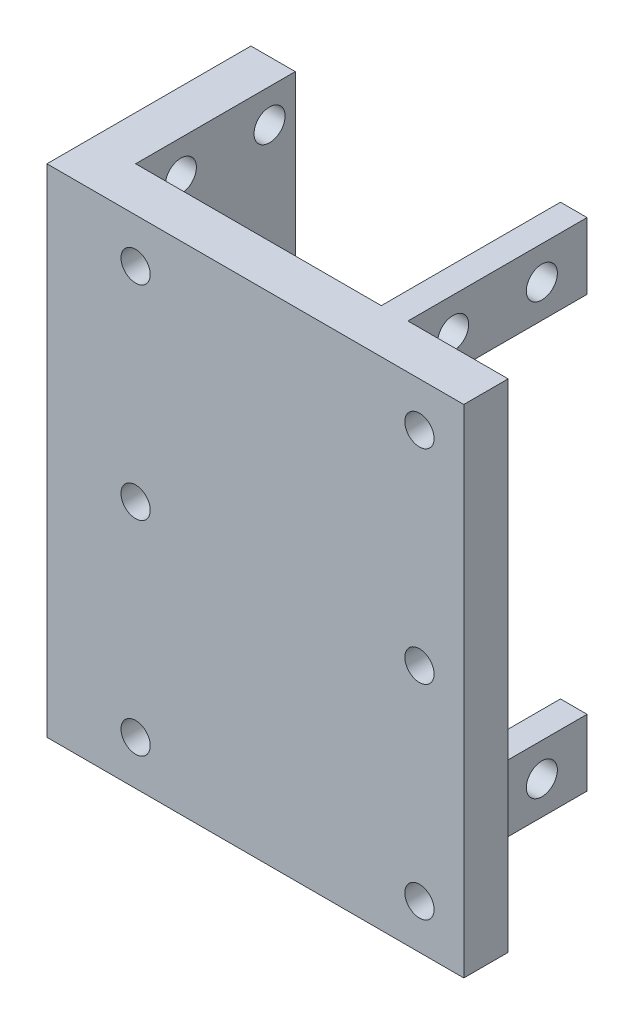
from build123d import *

# Parameters (mm, degrees)
SKETCH_1_W          = 42
SKETCH_1_H          = 56
EXTRUDE_1_DEPTH     = 5
SKETCH_2_W          = 5
SKETCH_2_H          = 56
EXTRUDE_2_DEPTH     = 23
SKETCH_3_W          = 3
SKETCH_3_H          = 7.5
EXTRUDE_3_DEPTH     = 20.2
SKETCH_4_R          = 1.75
CUT_EXTRUDE_1_DEPTH = 36.7
SKETCH_5_R          = 1.65
CUT_EXTRUDE_2_DEPTH = 10


with BuildPart() as part:
    # 草图1 → 凸台-拉伸1 (new body)
    with BuildSketch(Plane.XY):
        Rectangle(SKETCH_1_W, SKETCH_1_H)
    extrude(amount=EXTRUDE_1_DEPTH)

    # 草图2 → 凸台-拉伸2 (add)
    with BuildSketch(Plane.XY.offset(5)):
        with Locations((-23.5, 0)):
            Rectangle(SKETCH_2_W, SKETCH_2_H)
    extrude(amount=-EXTRUDE_2_DEPTH)

    # 草图3 → 凸台-拉伸3 (add)
    with BuildSketch(Plane(origin=(0, 0, 0), x_dir=(-1, 0, 0), z_dir=(0, 0, -1))):
        with Locations((-8.2, -24.25)):
            Rectangle(SKETCH_3_W, SKETCH_3_H)
        with Locations((-8.2, 24.25)):
            Rectangle(SKETCH_3_W, SKETCH_3_H)
    extrude(amount=EXTRUDE_3_DEPTH)

    # 草图4 → 切除-拉伸1 (cut, through all)
    with BuildSketch(Plane(origin=(9.7, 0, 0), x_dir=(0, 0, -1), z_dir=(1, 0, 0))):
        with Locations((5.1, 24.25)):
            Circle(SKETCH_4_R)
        with Locations((15.1, 24.25)):
            Circle(SKETCH_4_R)
        with Locations((15.1, -24.25)):
            Circle(SKETCH_4_R)
        with Locations((5.1, -24.25)):
            Circle(SKETCH_4_R)
    extrude(amount=-CUT_EXTRUDE_1_DEPTH, mode=Mode.SUBTRACT)

    # 草图5 → 切除-拉伸2 (cut)
    with BuildSketch(Plane(origin=(0, 0, 0), x_dir=(-1, 0, 0), z_dir=(0, 0, -1))):
        with Locations((-16, 23)):
            Circle(SKETCH_5_R)
        with Locations((-16, -23)):
            Circle(SKETCH_5_R)
        with Locations((16, -23)):
            Circle(SKETCH_5_R)
        with Locations((16, 23)):
            Circle(SKETCH_5_R)
        with Locations((16, 0)):
            Circle(SKETCH_5_R)
        with Locations((-16, 0)):
            Circle(SKETCH_5_R)
    extrude(amount=-CUT_EXTRUDE_2_DEPTH, mode=Mode.SUBTRACT)


solid = part.part
